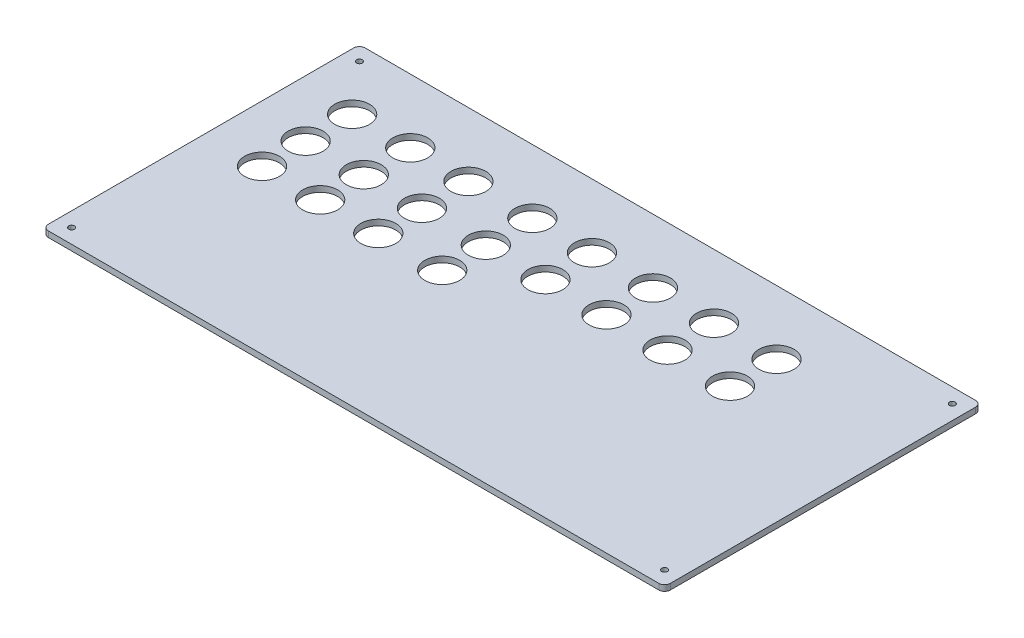
from build123d import *

# Parameters (mm, degrees)
BOSS_EXTRUDE1_DEPTH       = 2
SKETCH3_R                 = 6
CUT_EXTRUDE1_DEPTH        = 3
F_2_0MM_DOWEL_HOLE1_D     = 2
F_2_0MM_DOWEL_HOLE1_DEPTH = 8
F_2_0MM_DOWEL_HOLE1_TIP   = 0.600860619


with BuildPart() as part:
    # Sketch2 → Boss-Extrude1 (new body)
    with BuildSketch(Plane(origin=(0, 0, 0), x_dir=(1, 0, 0), z_dir=(0, 1, 0))):
        with BuildLine():
            Line((105, 54.5), (-105, 54.5))
            ThreePointArc((-105, 54.5), (-106.414213562, 53.914213562), (-107, 52.5))
            Line((-107, 52.5), (-107, -52.5))
            ThreePointArc((-107, -52.5), (-106.414213562, -53.914213562), (-105, -54.5))
            Line((-105, -54.5), (105, -54.5))
            ThreePointArc((105, -54.5), (106.414213562, -53.914213562), (107, -52.5))
            Line((107, -52.5), (107, 52.5))
            ThreePointArc((107, 52.5), (106.414213562, 53.914213562), (105, 54.5))
        make_face()
    extrude(amount=BOSS_EXTRUDE1_DEPTH)

    # Sketch3 → Cut-Extrude1 (cut)
    with BuildSketch(Plane(origin=(0, 2, 0), x_dir=(1, 0, 0), z_dir=(0, 1, 0))):
        with Locations((-87.5, 32.5)):
            Circle(SKETCH3_R)
        with Locations((-67.5, 32.5)):
            Circle(SKETCH3_R)
        with Locations((-47.5, 32.5)):
            Circle(SKETCH3_R)
        with Locations((-25.5, 32.5)):
            Circle(SKETCH3_R)
        with Locations((-5, 32.5)):
            Circle(SKETCH3_R)
        with Locations((16, 32.5)):
            Circle(SKETCH3_R)
        with Locations((37, 32.5)):
            Circle(SKETCH3_R)
        with Locations((58.5, 32.5)):
            Circle(SKETCH3_R)
        with Locations((-87.5, 16.5)):
            Circle(SKETCH3_R)
        with Locations((-67.5, 16.5)):
            Circle(SKETCH3_R)
        with Locations((-47.5, 16.5)):
            Circle(SKETCH3_R)
        with Locations((-25.5, 16.5)):
            Circle(SKETCH3_R)
        with Locations((-5, 16.5)):
            Circle(SKETCH3_R)
        with Locations((16, 16.5)):
            Circle(SKETCH3_R)
        with Locations((37, 16.5)):
            Circle(SKETCH3_R)
        with Locations((58.5, 16.5)):
            Circle(SKETCH3_R)
        with Locations((-67.5, 1.5)):
            Circle(SKETCH3_R)
        with Locations((-87.5, 1.5)):
            Circle(SKETCH3_R)
        with Locations((-47.5, 1.5)):
            Circle(SKETCH3_R)
        with Locations((-25.5, 1.5)):
            Circle(SKETCH3_R)
    extrude(amount=-CUT_EXTRUDE1_DEPTH, mode=Mode.SUBTRACT)

    # Ø2.0mm Dowel Hole1
    with Locations(Plane(origin=(0, 2, 0), x_dir=(1, 0, 0), z_dir=(0, 1, 0))):
        with Locations((-102, 49.5), (102, 49.5), (102, -49.5), (-102, -49.5)):
            Hole(F_2_0MM_DOWEL_HOLE1_D / 2, depth=F_2_0MM_DOWEL_HOLE1_DEPTH)
            with Locations((0, 0, -(F_2_0MM_DOWEL_HOLE1_DEPTH + F_2_0MM_DOWEL_HOLE1_TIP / 2))):  # 118° drill point
                Cone(0, F_2_0MM_DOWEL_HOLE1_D / 2, F_2_0MM_DOWEL_HOLE1_TIP, mode=Mode.SUBTRACT)


solid = part.part
